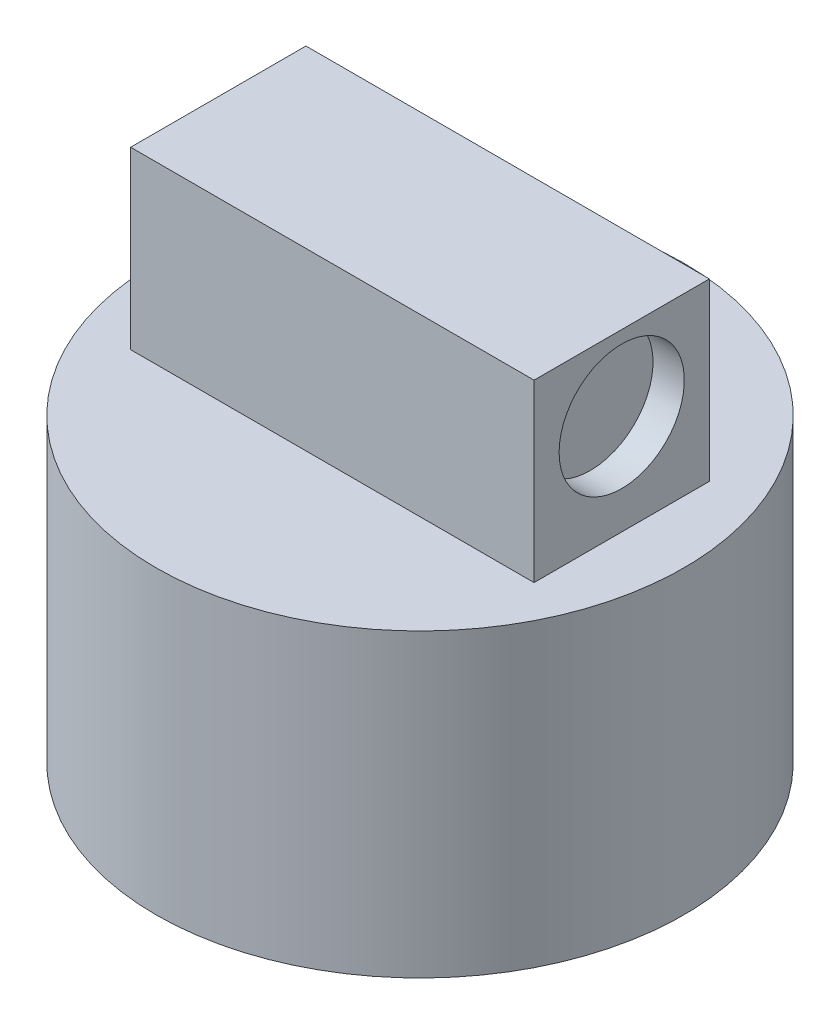
from build123d import *

# Parameters (mm, degrees)
SKETCH1_R           = 42.15
BOSS_EXTRUDE1_DEPTH = 48
SKETCH2_W           = 64.43
SKETCH2_H           = 28
BOSS_EXTRUDE2_DEPTH = 28
SKETCH3_R           = 10
CUT_EXTRUDE1_DEPTH  = 5


with BuildPart() as part:
    # Sketch1 → Boss-Extrude1 (new body)
    with BuildSketch(Plane(origin=(0, 0, 0), x_dir=(1, 0, 0), z_dir=(0, 1, 0))):
        with Locations((0, 5.951400749)):
            Circle(SKETCH1_R)
    extrude(amount=BOSS_EXTRUDE1_DEPTH)

    # Sketch2 → Boss-Extrude2 (add)
    with BuildSketch(Plane(origin=(0, 48, 0), x_dir=(1, 0, 0), z_dir=(0, 1, 0))):
        with Locations((0, 5.951400749)):
            Rectangle(SKETCH2_W, SKETCH2_H)
    extrude(amount=BOSS_EXTRUDE2_DEPTH)

    # Sketch3 → Cut-Extrude1 (cut)
    with BuildSketch(Plane.ZY.offset(32.215)):
        with Locations((-5.951400749, 64)):
            Circle(SKETCH3_R)
    cut_extrude1 = extrude(amount=-CUT_EXTRUDE1_DEPTH, mode=Mode.SUBTRACT)

    # Mirror2: Cut-Extrude1 across plane
    add(cut_extrude1.mirror(Plane.ZY), mode=Mode.SUBTRACT)


solid = part.part
